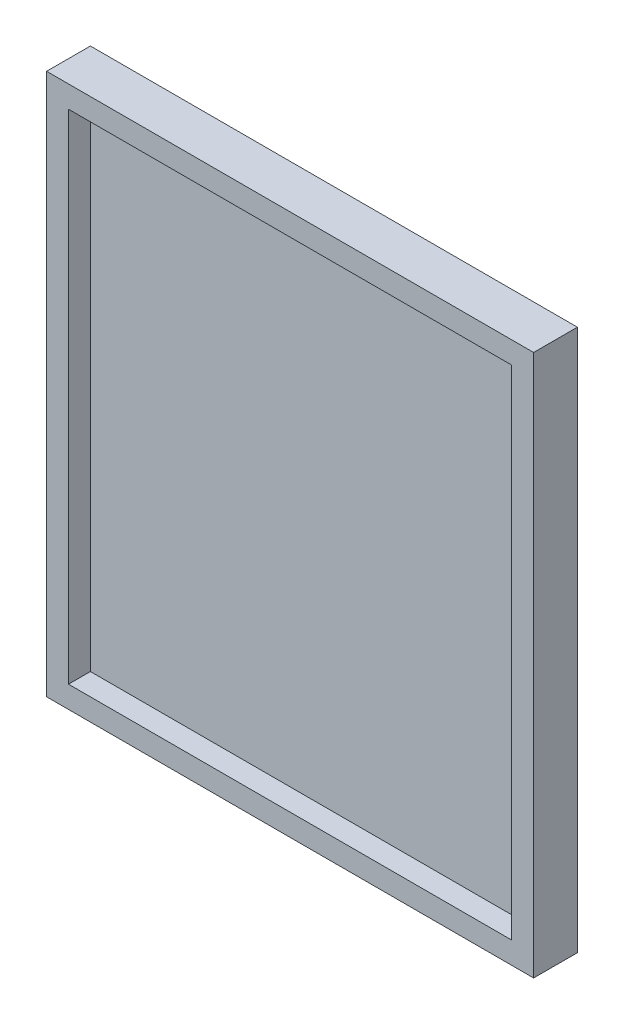
from build123d import *

# Parameters (mm, degrees)
SKETCH2_W           = 141.2875
SKETCH2_H           = 157.1625
BOSS_EXTRUDE1_DEPTH = 12.7
SHELL1_T            = -6.35


with BuildPart() as part:
    # Sketch2 → Boss-Extrude1 (new body)
    with BuildSketch(Plane.XY):
        Rectangle(SKETCH2_W, SKETCH2_H)
    extrude(amount=BOSS_EXTRUDE1_DEPTH)

    # Shell1
    shell1_openings = [part.faces().sort_by_distance(p)[0] for p in [
        (0, 0, 12.7),
    ]]
    offset(amount=SHELL1_T, openings=shell1_openings, kind=Kind.INTERSECTION)


solid = part.part
